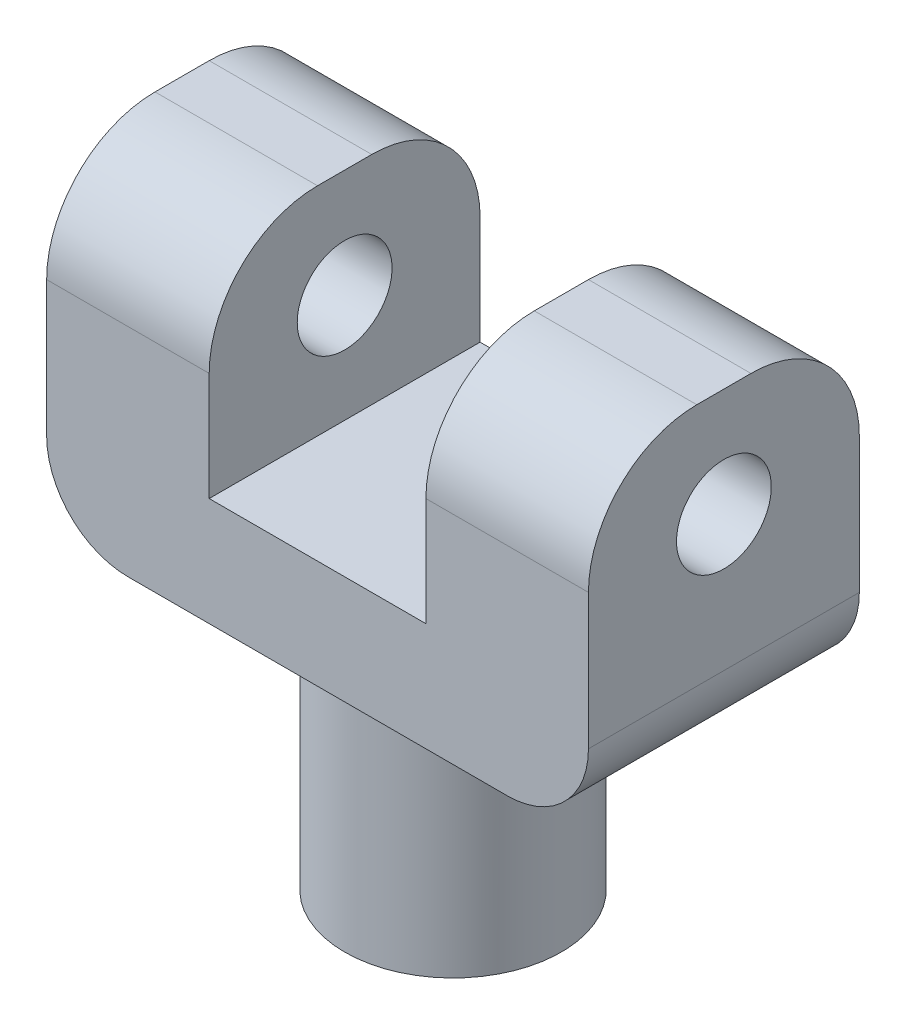
from build123d import *

# Parameters (mm, degrees)
SKETCH1_W           = 20
SKETCH1_H           = 10
BOSS_EXTRUDE1_DEPTH = 12
SKETCH2_W           = 8
SKETCH2_H           = 10
CUT_EXTRUDE1_DEPTH  = 8
FILLET1_R           = 4
SKETCH3_R           = 1.75
CUT_EXTRUDE2_DEPTH  = 21
FILLET2_R           = 3
SKETCH5_R           = 4
BOSS_EXTRUDE2_DEPTH = 9
SKETCH6_R           = 2
CUT_EXTRUDE3_DEPTH  = 7


with BuildPart() as part:
    # Sketch1 → Boss-Extrude1 (new body)
    with BuildSketch(Plane(origin=(0, 0, 0), x_dir=(1, 0, 0), z_dir=(0, 1, 0))):
        Rectangle(SKETCH1_W, SKETCH1_H)
    extrude(amount=BOSS_EXTRUDE1_DEPTH)

    # Sketch2 → Cut-Extrude1 (cut)
    with BuildSketch(Plane(origin=(0, 12, 0), x_dir=(1, 0, 0), z_dir=(0, 1, 0))):
        Rectangle(SKETCH2_W, SKETCH2_H)
    extrude(amount=-CUT_EXTRUDE1_DEPTH, mode=Mode.SUBTRACT)

    # Fillet1
    fillet1_edges = [part.edges().sort_by_distance(p)[0] for p in [
        (-7, 12, -5),
        (7, 12, 5),
        (-7, 12, 5),
        (7, 12, -5),
    ]]
    fillet(fillet1_edges, radius=FILLET1_R)

    # Sketch3 → Cut-Extrude2 (cut, through all)
    with BuildSketch(Plane.ZY.offset(10)):
        with Locations((0, 8)):
            Circle(SKETCH3_R)
    extrude(amount=-CUT_EXTRUDE2_DEPTH, mode=Mode.SUBTRACT)

    # Fillet2
    fillet2_edges = [part.edges().sort_by_distance(p)[0] for p in [
        (-10, 0, 0),
        (10, 0, 0),
    ]]
    fillet(fillet2_edges, radius=FILLET2_R)

    # Sketch5 → Boss-Extrude2 (add)
    with BuildSketch(Plane.XZ):
        Circle(SKETCH5_R)
    extrude(amount=BOSS_EXTRUDE2_DEPTH)

    # Sketch6 → Cut-Extrude3 (cut)
    with BuildSketch(Plane.XZ.offset(9)):
        Circle(SKETCH6_R)
    extrude(amount=-CUT_EXTRUDE3_DEPTH, mode=Mode.SUBTRACT)


solid = part.part
